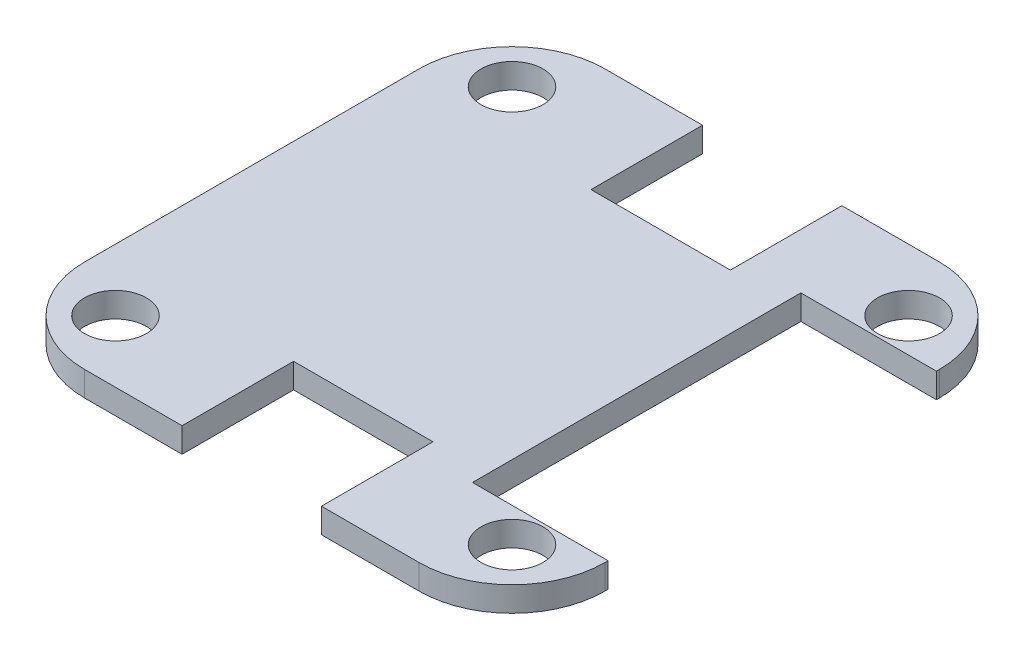
from build123d import *

# Parameters (mm, degrees)
BOSS_EXTRUDE1_DEPTH = 4
SKETCH4_W           = 21.88
SKETCH4_H           = 53
SKETCH4_R           = 5
CUT_EXTRUDE1_DEPTH  = 4


with BuildPart() as part:
    # Layer1 → Boss-Extrude1 (new body)
    with BuildSketch(Plane(origin=(0, 0, 0), x_dir=(1, 0, 0), z_dir=(0, 1, 0))):
        with BuildLine():
            Line((27, 42), (11.25, 42))
            Line((11.25, 42), (11.25, 24))
            Line((11.25, 24), (-11.25, 24))
            Line((-11.25, 24), (-11.25, 42))
            Line((-11.25, 42), (-27, 42))
            ThreePointArc((-27, 42), (-37.606601718, 37.606601718), (-42, 27))
            Line((-42, 27), (-42, 21.5))
            Line((-42, 21.5), (-42, -21.5))
            Line((-42, -21.5), (-42, -27))
            ThreePointArc((-42, -27), (-37.606601718, -37.606601718), (-27, -42))
            Line((-27, -42), (-11.25, -42))
            Line((-11.25, -42), (-11.25, -24))
            Line((-11.25, -24), (11.25, -24))
            Line((11.25, -24), (11.25, -42))
            Line((11.25, -42), (27, -42))
            ThreePointArc((27, -42), (37.606601718, -37.606601718), (42, -27))
            Line((42, -27), (42, 27))
            ThreePointArc((42, 27), (37.606601718, 37.606601718), (27, 42))
        make_face()
    extrude(amount=BOSS_EXTRUDE1_DEPTH)

    # Sketch4 → Cut-Extrude1 (cut)
    with BuildSketch(Plane(origin=(0, 4, 0), x_dir=(1, 0, 0), z_dir=(0, 1, 0))):
        with Locations((31.06, 0)):
            Rectangle(SKETCH4_W, SKETCH4_H)
        with Locations((32, 32)):
            Circle(SKETCH4_R)
        with Locations((-32, 32)):
            Circle(SKETCH4_R)
        with Locations((-32, -32)):
            Circle(SKETCH4_R)
        with Locations((32, -32)):
            Circle(SKETCH4_R)
    extrude(amount=-CUT_EXTRUDE1_DEPTH, mode=Mode.SUBTRACT)


solid = part.part
